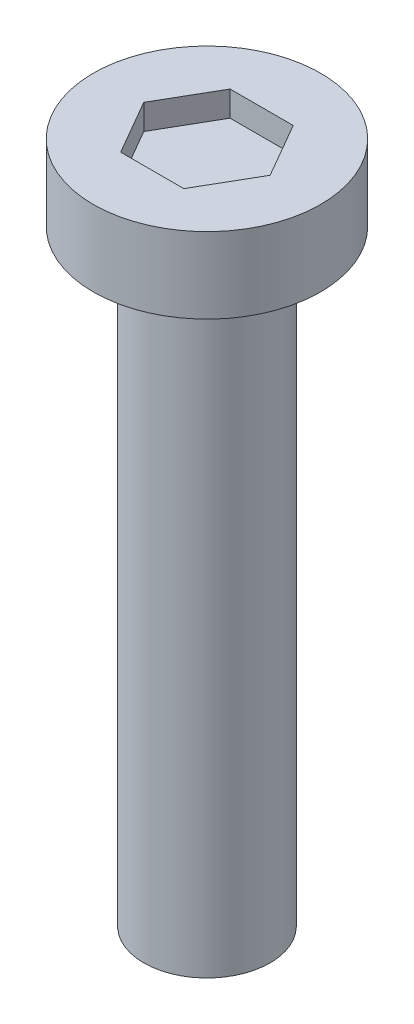
from build123d import *

# Parameters (mm, degrees)
SKETCH1_R           = 1.25
BOSS_EXTRUDE1_DEPTH = 12
SKETCH4_R           = 2.25
BOSS_EXTRUDE2_DEPTH = 1.5
CUT_EXTRUDE1_DEPTH  = 0.5


with BuildPart() as part:
    # Sketch1 → Boss-Extrude1 (new body)
    with BuildSketch(Plane(origin=(0, 0, 0), x_dir=(1, 0, 0), z_dir=(0, 1, 0))):
        Circle(SKETCH1_R)
    extrude(amount=BOSS_EXTRUDE1_DEPTH)

    # Sketch4 → Boss-Extrude2 (add)
    with BuildSketch(Plane(origin=(0, 12, 0), x_dir=(1, 0, 0), z_dir=(0, 1, 0))):
        Circle(SKETCH4_R)
    extrude(amount=BOSS_EXTRUDE2_DEPTH)

    # Sketch5 → Cut-Extrude1 (cut)
    with BuildSketch(Plane(origin=(0, 13.5, 0), x_dir=(1, 0, 0), z_dir=(0, 1, 0))):
        Polygon((1.25, 0), (0.625, 1.082531755), (-0.625, 1.082531755), (-1.25, 0), (-0.625, -1.082531755), (0.625, -1.082531755), align=None)
    extrude(amount=-CUT_EXTRUDE1_DEPTH, mode=Mode.SUBTRACT)


solid = part.part
